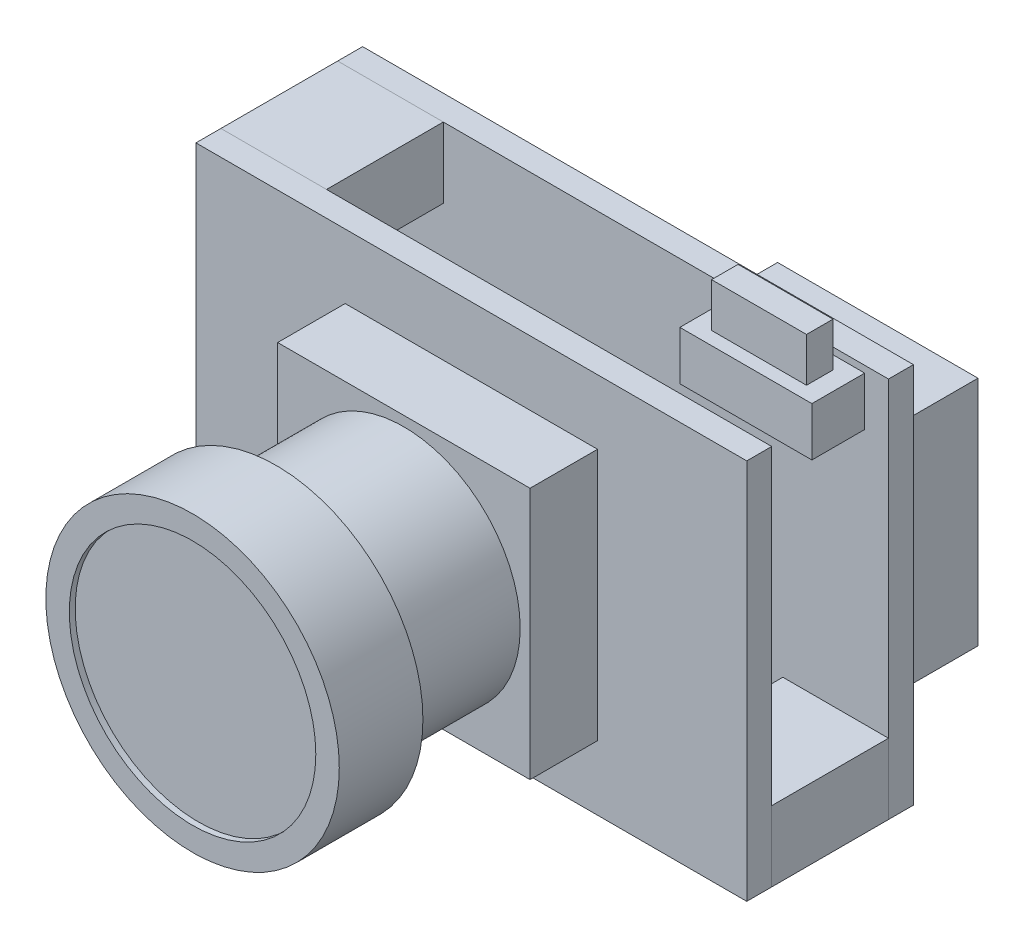
from build123d import *

# Parameters (mm, degrees)
SKETCH1_W             = 18.77
SKETCH1_H             = 13
BOSS_EXTRUDE1_DEPTH   = 0.85
SKETCH2_W             = 3.6
SKETCH2_H             = 2.4
BOSS_EXTRUDE2_DEPTH   = 3.98
BOSS_EXTRUDE2_2_DEPTH = 3.98
SKETCH3_W             = 18.77
SKETCH3_H             = 13
BOSS_EXTRUDE3_DEPTH   = 0.85
SKETCH4_W             = 8.6
SKETCH4_H             = 8.6
BOSS_EXTRUDE4_DEPTH   = 2.3
SKETCH5_R             = 3.965
BOSS_EXTRUDE5_DEPTH   = 4.35
SKETCH6_R             = 5
BOSS_EXTRUDE6_DEPTH   = 2.85
SKETCH7_R             = 4.2
CUT_EXTRUDE1_DEPTH    = 0.2
SKETCH8_W             = 6.83
SKETCH8_H             = 7.9
BOSS_EXTRUDE7_DEPTH   = 2.3
SKETCH9_W             = 6
SKETCH9_H             = 6
BOSS_EXTRUDE8_DEPTH   = 1
SKETCH10_W            = 4.5
SKETCH10_H            = 1.66423566
BOSS_EXTRUDE9_DEPTH   = 1.8
SKETCH11_W            = 3.234818436
SKETCH11_H            = 0.902158146
BOSS_EXTRUDE10_DEPTH  = 1.5
SKETCH12_W            = 2.417880197
SKETCH12_H            = 2.29029457
BOSS_EXTRUDE11_DEPTH  = 1.5
SKETCH13_R            = 0.45
BOSS_EXTRUDE13_DEPTH  = 4


with BuildPart() as part:
    # Sketch1 → Boss-Extrude1 (new body)
    with BuildSketch(Plane.XY):
        Rectangle(SKETCH1_W, SKETCH1_H)
    extrude(amount=BOSS_EXTRUDE1_DEPTH)

    # Sketch8 → Boss-Extrude7 (add)
    with BuildSketch(Plane(origin=(0, 0, 0), x_dir=(-1, 0, 0), z_dir=(0, 0, -1))):
        with Locations((-5.87, 0.95)):
            Rectangle(SKETCH8_W, SKETCH8_H)
    extrude(amount=BOSS_EXTRUDE7_DEPTH)

    # Sketch9 → Boss-Extrude8 (add)
    with BuildSketch(Plane(origin=(0, 0, 0), x_dir=(-1, 0, 0), z_dir=(0, 0, -1))):
        with Locations((2.351912758, -2.176373759)):
            Rectangle(SKETCH9_W, SKETCH9_H)
    extrude(amount=BOSS_EXTRUDE8_DEPTH)

    # Sketch10 → Boss-Extrude9 (add)
    with BuildSketch(Plane.XY.offset(0.85)):
        with Locations((6.324850122, 5.437990757)):
            Rectangle(SKETCH10_W, SKETCH10_H)
    extrude(amount=BOSS_EXTRUDE9_DEPTH)

    # Sketch11 → Boss-Extrude10 (add)
    with BuildSketch(Plane(origin=(0, 6.270108587, 0), x_dir=(1, 0, 0), z_dir=(0, 1, 0))):
        with Locations((6.324850122, -1.75)):
            Rectangle(SKETCH11_W, SKETCH11_H)
    extrude(amount=BOSS_EXTRUDE10_DEPTH)

    # Sketch12 → Boss-Extrude11 (add)
    with BuildSketch(Plane.XY.offset(0.85)):
        with Locations((-4.872863027, 0)):
            Rectangle(SKETCH12_W, SKETCH12_H)
    extrude(amount=BOSS_EXTRUDE11_DEPTH)

    # Sketch13 → Boss-Extrude13 (add)
    with BuildSketch(Plane.ZY.offset(6.081803125)):
        with Locations((1.6, 0.55)):
            Circle(SKETCH13_R)
        with Locations((1.6, -0.55)):
            Circle(SKETCH13_R)
    extrude(amount=BOSS_EXTRUDE13_DEPTH)


with BuildPart() as body_2:
    # Sketch2 → Boss-Extrude2 (new body)
    with BuildSketch(Plane.XY.offset(0.85)):
        with Locations((7.585, -5.3)):
            Rectangle(SKETCH2_W, SKETCH2_H)
    extrude(amount=BOSS_EXTRUDE2_DEPTH)


with BuildPart() as body_3:
    # Sketch2 → Boss-Extrude2 2 (new body)
    with BuildSketch(Plane.XY.offset(0.85)):
        with Locations((-7.585, 5.3)):
            Rectangle(SKETCH2_W, SKETCH2_H)
    extrude(amount=BOSS_EXTRUDE2_2_DEPTH)


with BuildPart() as body_4:
    # Sketch3 → Boss-Extrude3 (new body)
    with BuildSketch(Plane.XY.offset(4.83)):
        Rectangle(SKETCH3_W, SKETCH3_H)
    extrude(amount=BOSS_EXTRUDE3_DEPTH)


with BuildPart() as body_5:
    # Sketch4 → Boss-Extrude4 (new body)
    with BuildSketch(Plane.XY.offset(5.68)):
        Rectangle(SKETCH4_W, SKETCH4_H)
    extrude(amount=BOSS_EXTRUDE4_DEPTH)


with BuildPart() as body_6:
    # Sketch5 → Boss-Extrude5 (new body)
    with BuildSketch(Plane.XY.offset(7.98)):
        Circle(SKETCH5_R)
    extrude(amount=BOSS_EXTRUDE5_DEPTH)


with BuildPart() as body_7:
    # Sketch6 → Boss-Extrude6 (new body)
    with BuildSketch(Plane.XY.offset(12.33)):
        Circle(SKETCH6_R)
    extrude(amount=BOSS_EXTRUDE6_DEPTH)

    # Sketch7 → Cut-Extrude1 (cut)
    with BuildSketch(Plane.XY.offset(15.18)):
        Circle(SKETCH7_R)
    extrude(amount=-CUT_EXTRUDE1_DEPTH, mode=Mode.SUBTRACT)


solid = Compound([part.part, body_2.part, body_3.part, body_4.part, body_5.part, body_6.part, body_7.part])
